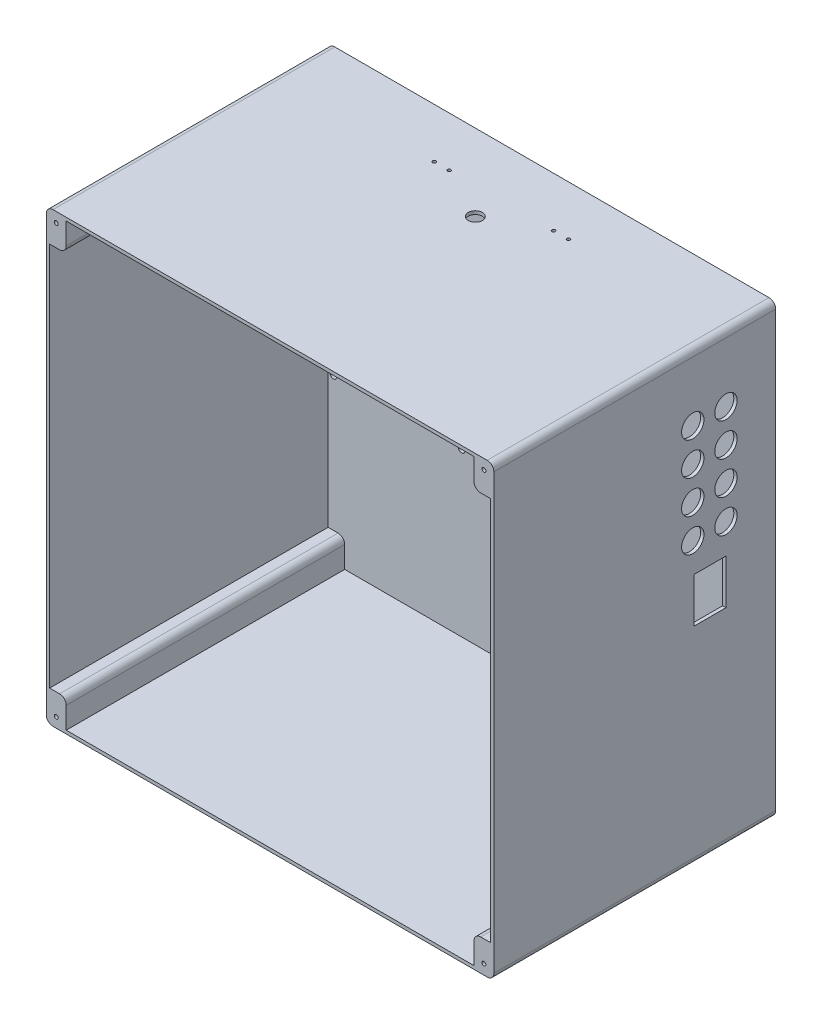
from build123d import *

# Parameters (mm, degrees)
ESQUISSE1_W                = 270
ESQUISSE1_H                = 270
EXTRUSION1_DEPTH           = 170
CONG_2_R                   = 4
EXTRUSION2_DEPTH           = 168
CONG_3_R                   = 4
TROU_TARAUD_4_481_D        = 2.3749
TROU_TARAUD_4_481_DEPTH    = 45
TROU_TARAUD_4_481_TIP      = 0.713491942
ESQUISSE5_W                = 14
ESQUISSE5_H                = 16
ENL_V_MAT_EXTRU_1_DEPTH    = 3
ESQUISSE6_R                = 6.75
ENL_V_MAT_EXTRU_6_DEPTH    = 10
R_P_TITION_LIN_AIRE3_COUNT = 4
R_P_TITION_LIN_AIRE3_PITCH = 20
ESQUISSE7_R                = 4.25
ENL_V_MAT_EXTRU_7_DEPTH    = 3
ESQUISSE8_R                = 2
ENL_V_MAT_EXTRU_8_DEPTH    = 171
ESQUISSE9_R                = 1
ENL_V_MAT_EXTRU_9_DEPTH    = 10
ESQUISSE10_W               = 19.2
ESQUISSE10_H               = 27
ENL_V_MAT_EXTRU_10_DEPTH   = 10
ESQUISSE11_R               = 5
ENL_V_MAT_EXTRU_11_DEPTH   = 10
ESQUISSE12_R               = 2
ENL_V_MAT_EXTRU_12_DEPTH   = 10


with BuildPart() as part:
    # Esquisse1 → Extrusion1 (new body)
    with BuildSketch(Plane.XY):
        with Locations((135, -135)):
            Rectangle(ESQUISSE1_W, ESQUISSE1_H)
    extrude(amount=EXTRUSION1_DEPTH)

    # Congé2
    cong_2_edges = [part.edges().sort_by_distance(p)[0] for p in [
        (0, 0, 85),
        (270, 0, 85),
        (270, -270, 85),
        (0, -270, 85),
    ]]
    fillet(cong_2_edges, radius=CONG_2_R)

    # Esquisse2 → Extrusion2 (cut)
    with BuildSketch(Plane.XY.offset(170)):
        Polygon((12, -2), (12, -19), (2, -19), (2, -251), (12, -251), (12, -268), (258, -268), (258, -251), (268, -251), (268, -19), (258, -19), (258, -2), align=None)
    extrude(amount=-EXTRUSION2_DEPTH, mode=Mode.SUBTRACT)

    # Congé3
    cong_3_edges = [part.edges().sort_by_distance(p)[0] for p in [
        (258, -19, 86),
        (258, -251, 86),
        (12, -251, 86),
        (12, -19, 86),
    ]]
    fillet(cong_3_edges, radius=CONG_3_R)

    # Trou taraudé #4-481
    with Locations(Plane(origin=(6, -6, 170), x_dir=(1, 0, 0), z_dir=(0, 0, 1))):
        with Locations((0, 0), (258, 0), (258, -258), (0, -258)):
            Hole(TROU_TARAUD_4_481_D / 2, depth=TROU_TARAUD_4_481_DEPTH)
            with Locations((0, 0, -(TROU_TARAUD_4_481_DEPTH + TROU_TARAUD_4_481_TIP / 2))):  # 118° drill point
                Cone(0, TROU_TARAUD_4_481_D / 2, TROU_TARAUD_4_481_TIP, mode=Mode.SUBTRACT)

    # Esquisse5 → Enlèv. mat.-Extru.1 (cut, through all)
    with BuildSketch(Plane(origin=(2, 0, 0), x_dir=(0, 0, -1), z_dir=(1, 0, 0))):
        with Locations((-40, -83.327995254)):
            Rectangle(ESQUISSE5_W, ESQUISSE5_H)
    extrude(amount=-ENL_V_MAT_EXTRU_1_DEPTH, mode=Mode.SUBTRACT)

    # Esquisse6 → Enlèv. mat.-Extru.6 (cut, symmetric)
    with BuildSketch(Plane(origin=(270, -440, 0), x_dir=(0, 0, -1), z_dir=(-1, 0, 0))):
        with Locations((-50, -400)):
            Circle(ESQUISSE6_R)
        with Locations((-30, -400)):
            Circle(ESQUISSE6_R)
    enl_v_mat_extru_6 = extrude(amount=ENL_V_MAT_EXTRU_6_DEPTH, both=True, mode=Mode.SUBTRACT)

    # Répétition linéaire3: Enlèv. mat.-Extru.6 ×4
    with Locations(*[(0, -i * R_P_TITION_LIN_AIRE3_PITCH, 0) for i in range(1, R_P_TITION_LIN_AIRE3_COUNT)]):
        add(enl_v_mat_extru_6, mode=Mode.SUBTRACT)

    # Esquisse7 → Enlèv. mat.-Extru.7 (cut)
    with BuildSketch(Plane(origin=(0, 0, 0), x_dir=(-1, 0, 0), z_dir=(0, 1, 0))):
        with Locations((-135, 46.2)):
            Circle(ESQUISSE7_R)
    extrude(amount=-ENL_V_MAT_EXTRU_7_DEPTH, mode=Mode.SUBTRACT)

    # Esquisse8 → Enlèv. mat.-Extru.8 (cut, through all)
    with BuildSketch(Plane(origin=(0, 0, 0), x_dir=(-1, 0, 0), z_dir=(0, 0, -1))):
        with Locations((-154.5, -50)):
            Circle(ESQUISSE8_R)
        with Locations((-115.5, -50)):
            Circle(ESQUISSE8_R)
        with Locations((-115.5, -90)):
            Circle(ESQUISSE8_R)
        with Locations((-154.5, -90)):
            Circle(ESQUISSE8_R)
    extrude(amount=-ENL_V_MAT_EXTRU_8_DEPTH, mode=Mode.SUBTRACT)

    # Esquisse9 → Enlèv. mat.-Extru.9 (cut)
    with BuildSketch(Plane(origin=(0, 0, 0), x_dir=(-1, 0, 0), z_dir=(0, 1, 0))):
        with Locations((-175, 30)):
            Circle(ESQUISSE9_R)
        with Locations((-166, 30)):
            Circle(ESQUISSE9_R)
        with Locations((-103, 30)):
            Circle(ESQUISSE9_R)
        with Locations((-94, 30)):
            Circle(ESQUISSE9_R)
    extrude(amount=-ENL_V_MAT_EXTRU_9_DEPTH, mode=Mode.SUBTRACT)

    # Esquisse10 → Enlèv. mat.-Extru.10 (cut)
    with BuildSketch(Plane(origin=(270, 0, 0), x_dir=(0, 0, -1), z_dir=(1, 0, 0))):
        with Locations((-39.6, -131.5)):
            Rectangle(ESQUISSE10_W, ESQUISSE10_H)
    extrude(amount=-ENL_V_MAT_EXTRU_10_DEPTH, mode=Mode.SUBTRACT)

    # Esquisse11 → Enlèv. mat.-Extru.11 (cut)
    with BuildSketch(Plane.XZ.offset(270)):
        with Locations((245, 10)):
            Circle(ESQUISSE11_R)
    extrude(amount=-ENL_V_MAT_EXTRU_11_DEPTH, mode=Mode.SUBTRACT)

    # Esquisse12 → Enlèv. mat.-Extru.12 (cut)
    with BuildSketch(Plane.XY.offset(2)):
        with Locations((82.5, -31.834379135)):
            Circle(ESQUISSE12_R)
        with Locations((5.5, -31.834379135)):
            Circle(ESQUISSE12_R)
        with Locations((5.192317745, -169.834379135)):
            Circle(ESQUISSE12_R)
        with Locations((82.5, -169.834379135)):
            Circle(ESQUISSE12_R)
    extrude(amount=-ENL_V_MAT_EXTRU_12_DEPTH, mode=Mode.SUBTRACT)


solid = part.part
